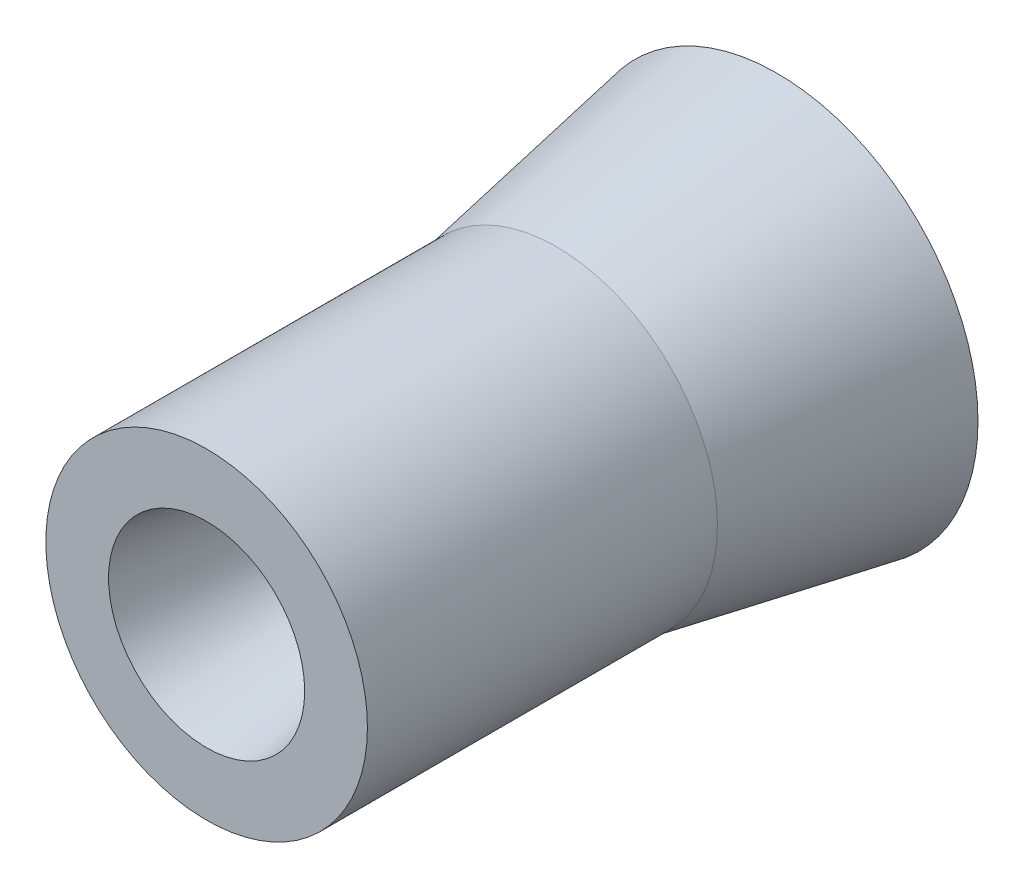
from build123d import *


with BuildPart() as part:
    # Sketch1 → Revolve-Thin1 (revolve)
    with BuildSketch(Plane(origin=(0, 0, 0), x_dir=(0, 0, -1), z_dir=(1, 0, 0))):
        Polygon((2433.826246914, 385.88150306), (2433.826246914, 334.771392049), (2541.94019818, 314.975879845), (2735.520516837, 314.975879845), (2898.727447068, 368.64302357), (2898.727447068, 418.546471621), (2719.070119986, 385.88150306), align=None)
        Polygon((2443.826246914, 375.88150306), (2443.826246914, 343.106649757), (2542.848144127, 324.975879845), (2733.918565509, 324.975879845), (2888.727447068, 375.88150306), (2888.727447068, 406.56434445), (2719.971819423, 375.88150306), align=None, mode=Mode.SUBTRACT)
    revolve(axis=Axis((0, 254.852892636, -1616.565391775), (0, 0, -1)))


solid = part.part
